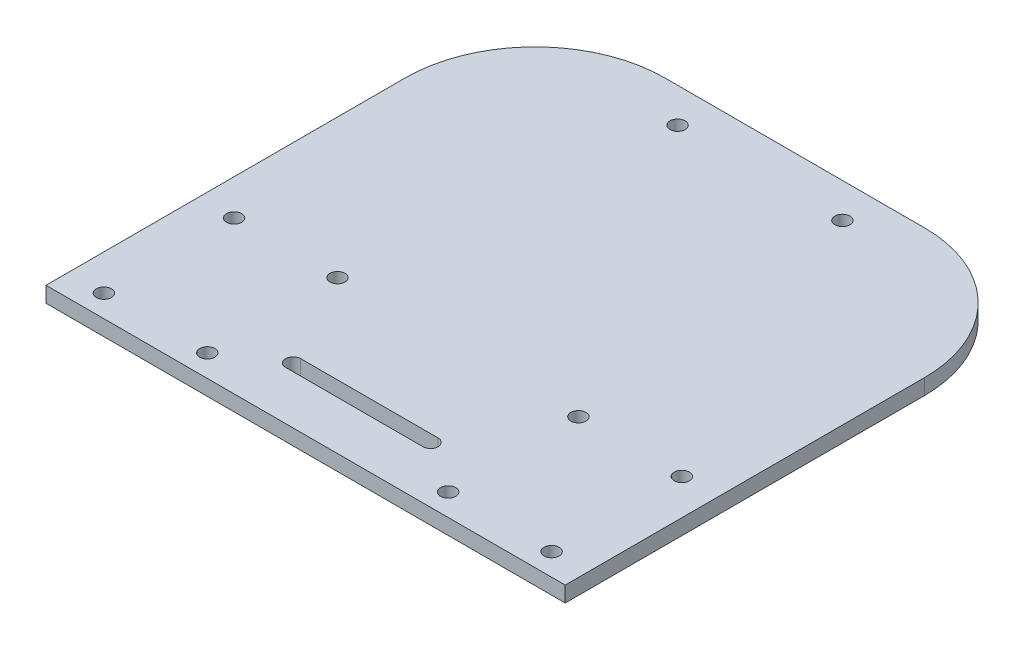
from build123d import *

# Parameters (mm, degrees)
SKETCH_6_W      = 120
SKETCH_6_H      = 113.017251625
SKETCH_6_R      = 1.75
EXTRUDE_2_DEPTH = 3.6
FILLET_1_R      = 30
FILLET_2_R      = 30


with BuildPart() as part:
    # 草图6 → 凸台-拉伸2 (new body)
    with BuildSketch(Plane(origin=(0, 0, 0), x_dir=(1, 0, 0), z_dir=(0, 1, 0))):
        with Locations((95, 83.491374187)):
            Rectangle(SKETCH_6_W, SKETCH_6_H)
        with Locations((43.263065037, 32.093294966)):
            Circle(SKETCH_6_R, mode=Mode.SUBTRACT)
        with Locations((67.163065037, 32.093294966)):
            Circle(SKETCH_6_R, mode=Mode.SUBTRACT)
        with BuildLine():
            ThreePointArc((79.1225441, 38.232748375), (77.3725441, 39.982748375), (79.1225441, 41.732748375))
            Line((79.1225441, 41.732748375), (110.8774559, 41.732748375))
            ThreePointArc((110.8774559, 41.732748375), (112.6274559, 39.982748375), (110.8774559, 38.232748375))
            Line((110.8774559, 38.232748375), (79.1225441, 38.232748375))
        make_face(mode=Mode.SUBTRACT)
        with Locations((43.263065037, 62.193294966)):
            Circle(SKETCH_6_R, mode=Mode.SUBTRACT)
        with Locations((67.163065037, 62.193294966)):
            Circle(SKETCH_6_R, mode=Mode.SUBTRACT)
        with Locations((75.95, 132)):
            Circle(SKETCH_6_R, mode=Mode.SUBTRACT)
        with Locations((114.05, 132)):
            Circle(SKETCH_6_R, mode=Mode.SUBTRACT)
        with Locations((122.836934963, 62.193294966)):
            Circle(SKETCH_6_R, mode=Mode.SUBTRACT)
        with Locations((122.836934963, 32.093294966)):
            Circle(SKETCH_6_R, mode=Mode.SUBTRACT)
        with Locations((146.736934963, 32.093294966)):
            Circle(SKETCH_6_R, mode=Mode.SUBTRACT)
        with Locations((146.736934963, 62.193294966)):
            Circle(SKETCH_6_R, mode=Mode.SUBTRACT)
    extrude(amount=EXTRUDE_2_DEPTH)

    # 圆角1
    fillet_1_edges = [part.edges().sort_by_distance(p)[0] for p in [
        (35, 1.8, -140),
    ]]
    fillet(fillet_1_edges, radius=FILLET_1_R)

    # 圆角2
    fillet_2_edges = [part.edges().sort_by_distance(p)[0] for p in [
        (155, 1.8, -140),
    ]]
    fillet(fillet_2_edges, radius=FILLET_2_R)


solid = part.part
